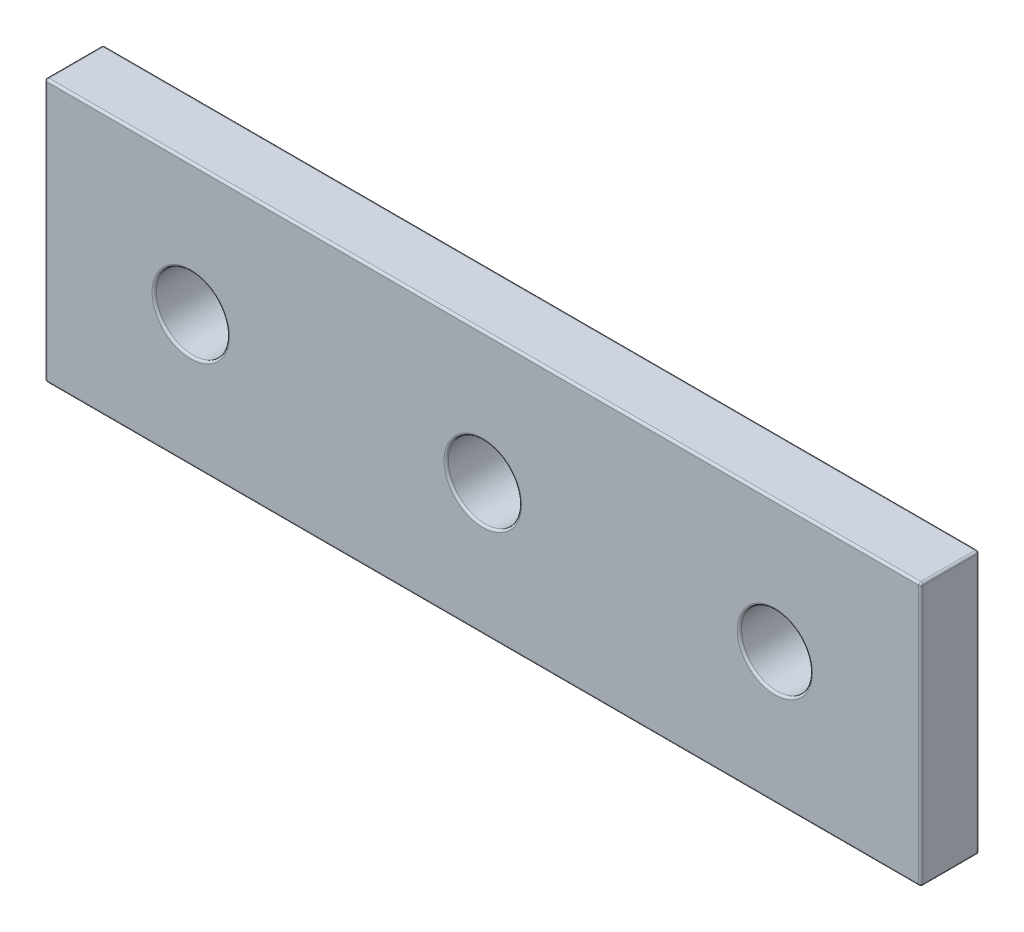
from build123d import *

# Parameters (mm, degrees)
SKETCH1_W           = 60
SKETCH1_H           = 18
SKETCH1_R           = 2.5
SKETCH1_R_2         = 2.425824168
BOSS_EXTRUDE1_DEPTH = 4
FILLET1_R           = 0.15


with BuildPart() as part:
    # Sketch1 → Boss-Extrude1 (new body)
    with BuildSketch(Plane.XY):
        Rectangle(SKETCH1_W, SKETCH1_H)
        Circle(SKETCH1_R, mode=Mode.SUBTRACT)
        with Locations((20, 0)):
            Circle(SKETCH1_R_2, mode=Mode.SUBTRACT)
        with Locations((-20, 0)):
            Circle(SKETCH1_R, mode=Mode.SUBTRACT)
    extrude(amount=BOSS_EXTRUDE1_DEPTH)

    # Fillet1
    fillet1_edges = [part.edges().sort_by_distance(p)[0] for p in [
        (30, 0, 4),
        (-2.5, 0, 0),
        (-2.5, 0, 4),
        (0, 9, 4),
        (-22.5, 0, 0),
        (-22.5, 0, 4),
        (17.574175832, 0, 0),
        (17.574175832, 0, 4),
        (-30, 0, 4),
        (0, 9, 0),
        (30, 0, 0),
        (0, -9, 0),
        (-30, 0, 0),
        (0, -9, 4),
        (-30, 9, 2),
        (30, 9, 2),
        (30, -9, 2),
        (-30, -9, 2),
    ]]
    fillet(fillet1_edges, radius=FILLET1_R)


solid = part.part
